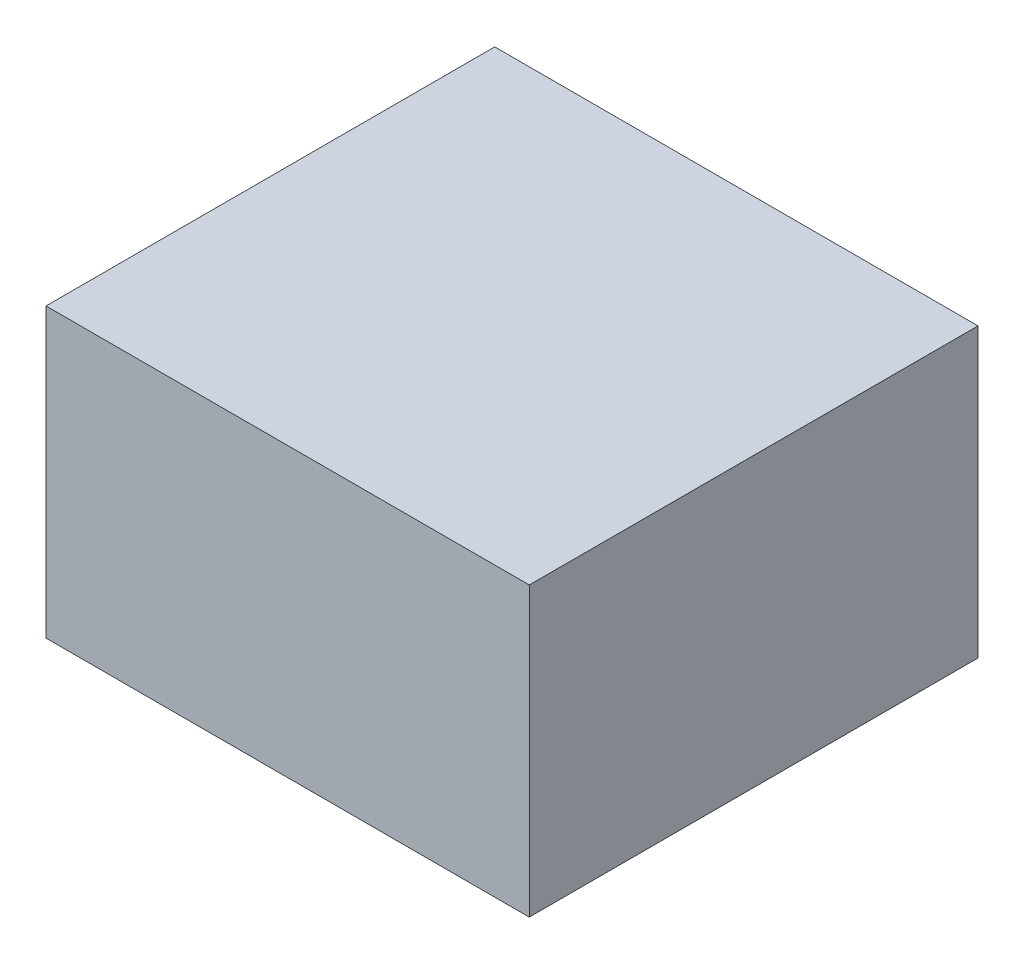
from build123d import *

# Parameters (mm, degrees)
SKETCH1_W           = 84
SKETCH1_H           = 78
BOSS_EXTRUDE1_DEPTH = 50


with BuildPart() as part:
    # Sketch1 → Boss-Extrude1 (new body)
    with BuildSketch(Plane(origin=(0, 0, 0), x_dir=(1, 0, 0), z_dir=(0, 1, 0))):
        with Locations((42, 39)):
            Rectangle(SKETCH1_W, SKETCH1_H)
    extrude(amount=BOSS_EXTRUDE1_DEPTH)


solid = part.part
